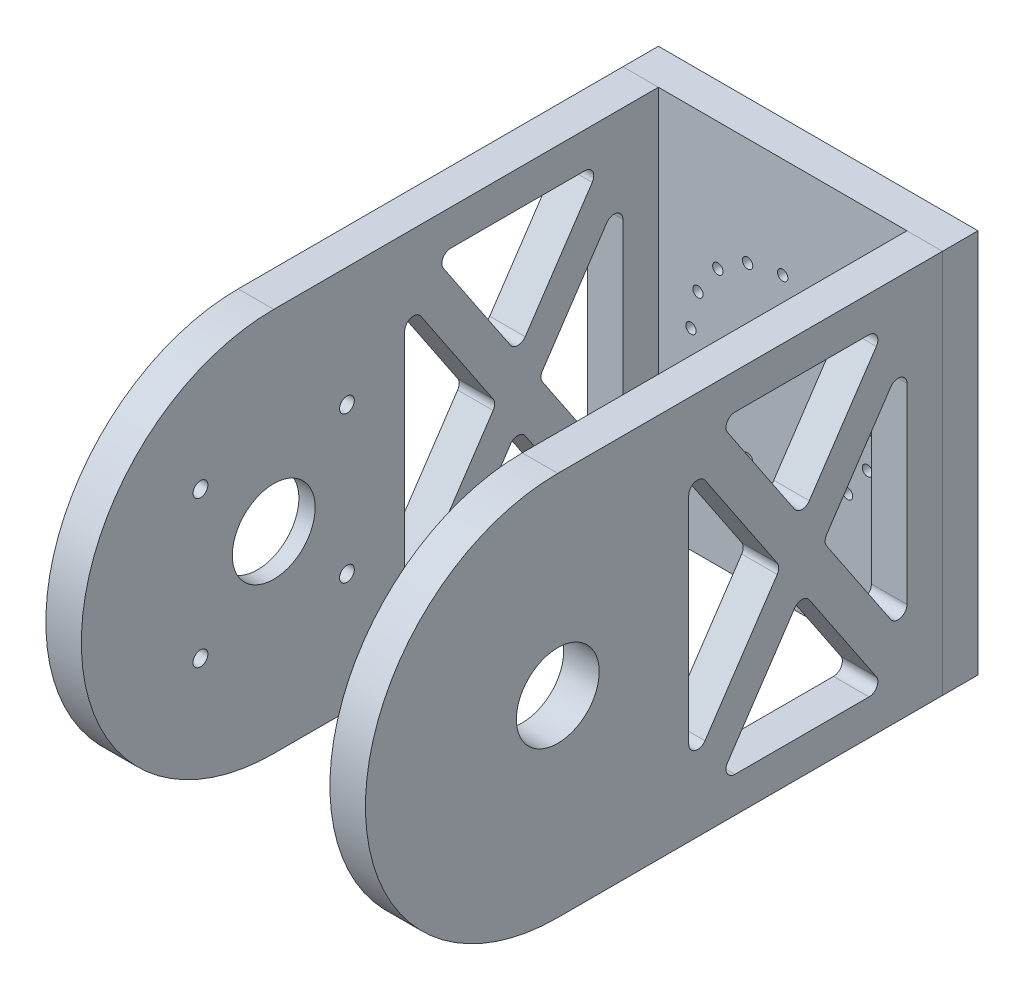
from build123d import *

# Parameters (mm, degrees)
SKETCH1_R               = 14
BOSS_EXTRUDE1_DEPTH     = 12
SKETCH2_W               = 130
SKETCH2_H               = 12
BOSS_EXTRUDE2_DEPTH     = 108
CUT_EXTRUDE1_START      = -108
SKETCH3_W               = 70
SKETCH3_H               = 70
CUT_EXTRUDE1_DEPTH      = 3
SKETCH4_R               = 2.5
CUT_EXTRUDE2_DEPTH      = 25
SKETCH5_R               = 25
CUT_EXTRUDE3_DEPTH      = 3.5
FILLET1_R               = 6
SKETCH7_R               = 1.75
CUT_EXTRUDE5_DEPTH      = 65
CUT_EXTRUDE6_DEPTH      = 1
CUT_EXTRUDE6_DEPTH_BACK = 109


with BuildPart() as part:
    # Sketch1 → Boss-Extrude1 (new body)
    with BuildSketch(Plane.YZ):
        with BuildLine():
            Line((65, 0), (65, -130))
            Line((65, -130), (-65, -130))
            Line((-65, -130), (-65, 0))
            ThreePointArc((-65, 0), (0, 65), (65, 0))
        make_face()
        Circle(SKETCH1_R, mode=Mode.SUBTRACT)
    extrude(amount=BOSS_EXTRUDE1_DEPTH)


with BuildPart() as body_2:
    # Sketch2 → Boss-Extrude2 (new body)
    with BuildSketch(Plane.YZ):
        with Locations((0, -136)):
            Rectangle(SKETCH2_W, SKETCH2_H)
    extrude(amount=BOSS_EXTRUDE2_DEPTH)

    # Sketch7 → Cut-Extrude5 (cut)
    with BuildSketch(Plane(origin=(0, 0, -142), x_dir=(1, 0, 0), z_dir=(0, 0, -1))):
        with Locations((54, 31)):
            Circle(SKETCH7_R)
        with Locations((65.863186403, 28.640265508)):
            Circle(SKETCH7_R)
        with Locations((75.920310217, 21.920310217)):
            Circle(SKETCH7_R)
        with Locations((82.640265508, 11.863186403)):
            Circle(SKETCH7_R)
        with Locations((85, 0)):
            Circle(SKETCH7_R)
        with Locations((82.640265508, -11.863186403)):
            Circle(SKETCH7_R)
        with Locations((75.920310217, -21.920310217)):
            Circle(SKETCH7_R)
        with Locations((65.863186403, -28.640265508)):
            Circle(SKETCH7_R)
        with Locations((54, -31)):
            Circle(SKETCH7_R)
        with Locations((42.136813597, -28.640265508)):
            Circle(SKETCH7_R)
        with Locations((32.079689783, -21.920310217)):
            Circle(SKETCH7_R)
        with Locations((25.359734492, -11.863186403)):
            Circle(SKETCH7_R)
        with Locations((23, 0)):
            Circle(SKETCH7_R)
        with Locations((25.359734492, 11.863186403)):
            Circle(SKETCH7_R)
        with Locations((32.079689783, 21.920310217)):
            Circle(SKETCH7_R)
        with Locations((42.136813597, 28.640265508)):
            Circle(SKETCH7_R)
    extrude(amount=-CUT_EXTRUDE5_DEPTH, mode=Mode.SUBTRACT)


with BuildPart() as body_3:
    # Mirror1: mirrored copy
    add(part.part.mirror(Plane(origin=(54, 0, 0), x_dir=(0, 0, 1), z_dir=(1, 0, 0))))


with BuildPart() as part_1:
    add(part.part)

    # Sketch3 → Cut-Extrude1 (cut)
    with BuildSketch(Plane.YZ.offset(108).offset(CUT_EXTRUDE1_START)):
        Rectangle(SKETCH3_W, SKETCH3_H)
    extrude(amount=CUT_EXTRUDE1_DEPTH, mode=Mode.SUBTRACT)

    # Sketch4 → Cut-Extrude2 (cut)
    with BuildSketch(Plane(origin=(0, 0, 0), x_dir=(0, -1, 0), z_dir=(-1, 0, 0))):
        with Locations((-24.748737342, 24.748737342)):
            Circle(SKETCH4_R)
        with Locations((24.748737342, 24.748737342)):
            Circle(SKETCH4_R)
        with Locations((24.748737342, -24.748737342)):
            Circle(SKETCH4_R)
        with Locations((-24.748737342, -24.748737342)):
            Circle(SKETCH4_R)
    extrude(amount=-CUT_EXTRUDE2_DEPTH, mode=Mode.SUBTRACT)

    # Sketch5 → Cut-Extrude3 (cut)
    with BuildSketch(Plane(origin=(3, 0, 0), x_dir=(0, -1, 0), z_dir=(-1, 0, 0))):
        Circle(SKETCH5_R)
    extrude(amount=-CUT_EXTRUDE3_DEPTH, mode=Mode.SUBTRACT)

    # Fillet1
    fillet1_edges = [part_1.edges().sort_by_distance(p)[0] for p in [
        (1.5, 35, -35),
        (1.5, 35, 35),
        (1.5, -35, 35),
        (1.5, -35, -35),
    ]]
    fillet(fillet1_edges, radius=FILLET1_R)


with BuildPart() as cut_extrude6_tool:
    # Sketch8 → Cut-Extrude6 (new body, two sides)
    with BuildSketch(Plane(origin=(0, 0, 0), x_dir=(0, -1, 0), z_dir=(-1, 0, 0))) as cut_extrude6_sk:
        with BuildLine():
            Line((-36.452273402, -44.251476123), (36.452273402, -44.251476123))
            ThreePointArc((36.452273402, -44.251476123), (39.322602839, -46.379003244), (38.121796461, -49.744003507))
            Line((38.121796461, -49.744003507), (1.669523059, -74.160148899))
            ThreePointArc((1.669523059, -74.160148899), (0, -74.667621515), (-1.669523059, -74.160148899))
            Line((-1.669523059, -74.160148899), (-38.121796461, -49.744003507))
            ThreePointArc((-38.121796461, -49.744003507), (-39.322602839, -46.379003244), (-36.452273402, -44.251476123))
        make_face()
        with BuildLine():
            Line((-53, -59.841812447), (-53, -105.158187553))
            ThreePointArc((-53, -105.158187553), (-51.41269792, -107.804748451), (-48.330476941, -107.650714936))
            Line((-48.330476941, -107.650714936), (-14.502760313, -84.992527383))
            ThreePointArc((-14.502760313, -84.992527383), (-13.172283372, -82.5), (-14.502760313, -80.007472617))
            Line((-14.502760313, -80.007472617), (-48.330476941, -57.349285064))
            ThreePointArc((-48.330476941, -57.349285064), (-51.41269792, -57.195251549), (-53, -59.841812447))
        make_face()
        with BuildLine():
            Line((-32.348843389, -118), (32.348843389, -118))
            ThreePointArc((32.348843389, -118), (35.219172826, -115.872472879), (34.018366448, -112.507472617))
            Line((34.018366448, -112.507472617), (1.669523059, -90.839851101))
            ThreePointArc((1.669523059, -90.839851101), (0, -90.332378485), (-1.669523059, -90.839851101))
            Line((-1.669523059, -90.839851101), (-34.018366448, -112.507472617))
            ThreePointArc((-34.018366448, -112.507472617), (-35.219172826, -115.872472879), (-32.348843389, -118))
        make_face()
        with BuildLine():
            Line((53, -59.841812447), (53, -105.158187553))
            ThreePointArc((53, -105.158187553), (51.41269792, -107.804748451), (48.330476941, -107.650714936))
            Line((48.330476941, -107.650714936), (14.502760313, -84.992527383))
            ThreePointArc((14.502760313, -84.992527383), (13.172283372, -82.5), (14.502760313, -80.007472617))
            Line((14.502760313, -80.007472617), (48.330476941, -57.349285064))
            ThreePointArc((48.330476941, -57.349285064), (51.41269792, -57.195251549), (53, -59.841812447))
        make_face()
    extrude(amount=CUT_EXTRUDE6_DEPTH)
    extrude(cut_extrude6_sk.sketch, amount=-CUT_EXTRUDE6_DEPTH_BACK)


with BuildPart() as part_2:
    add(part_1.part)

    # Cut-Extrude6: cut by cut_extrude6_tool
    add(cut_extrude6_tool.part, mode=Mode.SUBTRACT)


with BuildPart() as body_3_1:
    add(body_3.part)

    # Cut-Extrude6: cut by cut_extrude6_tool
    add(cut_extrude6_tool.part, mode=Mode.SUBTRACT)


solid = Compound([body_2.part, part_2.part, body_3_1.part])
